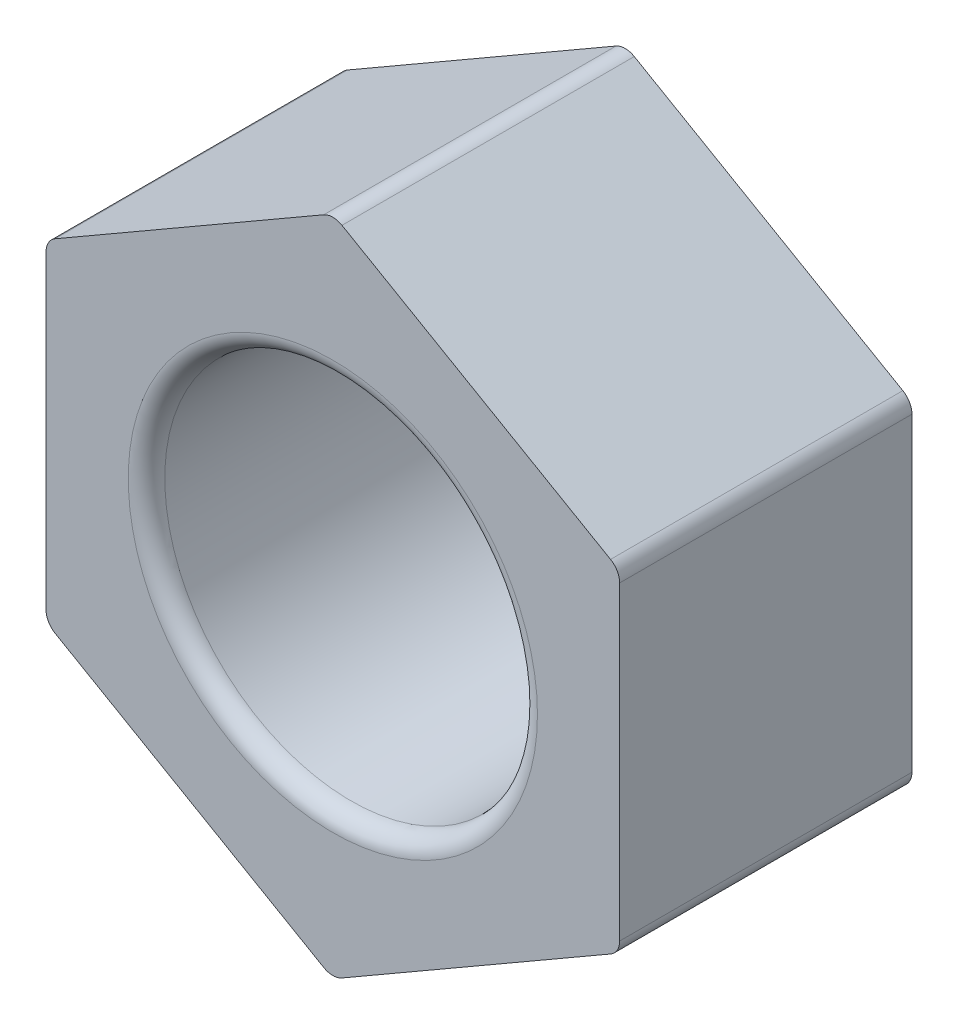
from build123d import *

# Parameters (mm, degrees)
BOSS_EXTRUDE1_DEPTH = 4
SKETCH2_R           = 2.55
CUT_EXTRUDE1_DEPTH  = 5
FILLET1_R           = 0.25


with BuildPart() as part:
    # Sketch1 → Boss-Extrude1 (new body)
    with BuildSketch(Plane.XY):
        Polygon((0, 4.532199613), (-3.925, 2.266099807), (-3.925, -2.266099807), (0, -4.532199613), (3.925, -2.266099807), (3.925, 2.266099807), align=None)
    extrude(amount=BOSS_EXTRUDE1_DEPTH)

    # Sketch2 → Cut-Extrude1 (cut, through all)
    with BuildSketch(Plane.XY.offset(4)):
        Circle(SKETCH2_R)
    extrude(amount=-CUT_EXTRUDE1_DEPTH, mode=Mode.SUBTRACT)

    # Fillet1
    fillet1_edges = [part.edges().sort_by_distance(p)[0] for p in [
        (3.925, 2.266099807, 2),
        (3.925, -2.266099807, 2),
        (0, -4.532199613, 2),
        (-3.925, -2.266099807, 2),
        (-3.925, 2.266099807, 2),
        (0, 4.532199613, 2),
        (-2.55, 0, 0),
        (-2.55, 0, 4),
    ]]
    fillet(fillet1_edges, radius=FILLET1_R)


solid = part.part
